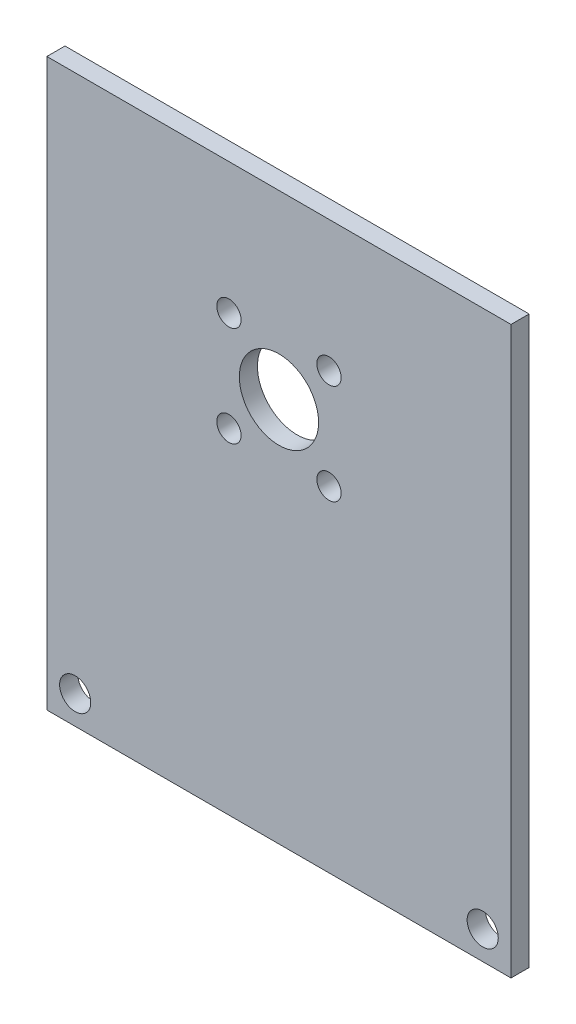
from build123d import *

# Parameters (mm, degrees)
SKETCH1_W           = 150
SKETCH1_H           = 160
BOSS_EXTRUDE1_DEPTH = 3.2
CUT_EXTRUDE1_REACH  = 5.2
SKETCH2_R           = 7
SKETCH2_R_2         = 2.75
SKETCH3_R           = 2.15
CUT_EXTRUDE2_DEPTH  = 4.2
CIRPATTERN1_COUNT   = 4
SKETCH5_OUTSIDE_W   = 195.868
SKETCH5_OUTSIDE_H   = 205.868
SKETCH5_OUTSIDE_W_2 = 82
SKETCH5_OUTSIDE_H_2 = 100
CUT_EXTRUDE4_DEPTH  = 10


with BuildPart() as part:
    # Sketch1 → Boss-Extrude1 (new body)
    with BuildSketch(Plane.XY):
        Rectangle(SKETCH1_W, SKETCH1_H)
    extrude(amount=BOSS_EXTRUDE1_DEPTH)

    # Sketch2 → Cut-Extrude1 (cut, up to next)
    with BuildSketch(Plane.XY.offset(3.2), mode=Mode.PRIVATE) as cut_extrude1_sk1:
        with Locations((0, -12)):
            Circle(SKETCH2_R)
    cut_extrude1_tool1 = extrude(cut_extrude1_sk1.sketch, amount=-CUT_EXTRUDE1_REACH, mode=Mode.PRIVATE) & part.part
    add(cut_extrude1_tool1.solids().sort_by_distance((0, -12, 3.2))[0], mode=Mode.SUBTRACT)
    # Sketch2 → Cut-Extrude1 (cut, up to next)
    with BuildSketch(Plane.XY.offset(3.2), mode=Mode.PRIVATE) as cut_extrude1_sk2:
        with Locations((-36, -75)):
            Circle(SKETCH2_R_2)
    cut_extrude1_tool2 = extrude(cut_extrude1_sk2.sketch, amount=-CUT_EXTRUDE1_REACH, mode=Mode.PRIVATE) & part.part
    add(cut_extrude1_tool2.solids().sort_by_distance((-36, -75, 3.2))[0], mode=Mode.SUBTRACT)
    # Sketch2 → Cut-Extrude1 (cut, up to next)
    with BuildSketch(Plane.XY.offset(3.2), mode=Mode.PRIVATE) as cut_extrude1_sk3:
        with Locations((36, -75)):
            Circle(SKETCH2_R_2)
    cut_extrude1_tool3 = extrude(cut_extrude1_sk3.sketch, amount=-CUT_EXTRUDE1_REACH, mode=Mode.PRIVATE) & part.part
    add(cut_extrude1_tool3.solids().sort_by_distance((36, -75, 3.2))[0], mode=Mode.SUBTRACT)

    # Sketch3 → Cut-Extrude2 (cut, through all)
    with BuildSketch(Plane.XY.offset(3.2)):
        with Locations((-8.838834765, -3.161165235)):
            Circle(SKETCH3_R)
    cut_extrude2 = extrude(amount=-CUT_EXTRUDE2_DEPTH, mode=Mode.SUBTRACT)

    # CirPattern1: Cut-Extrude2 ×4 about axis
    cirpattern1_axis = Axis((0, -12, 0), (0, 0, 1))
    for i in range(1, CIRPATTERN1_COUNT):
        add(cut_extrude2.rotate(cirpattern1_axis, i * 360 / CIRPATTERN1_COUNT), mode=Mode.SUBTRACT)

    # Sketch5 outside → Cut-Extrude4 (cut)
    with BuildSketch(Plane.XY.offset(3.2)):
        Rectangle(SKETCH5_OUTSIDE_W, SKETCH5_OUTSIDE_H)
        with Locations((0, -30)):
            Rectangle(SKETCH5_OUTSIDE_W_2, SKETCH5_OUTSIDE_H_2, mode=Mode.SUBTRACT)
    extrude(amount=-CUT_EXTRUDE4_DEPTH, mode=Mode.SUBTRACT)


solid = part.part
